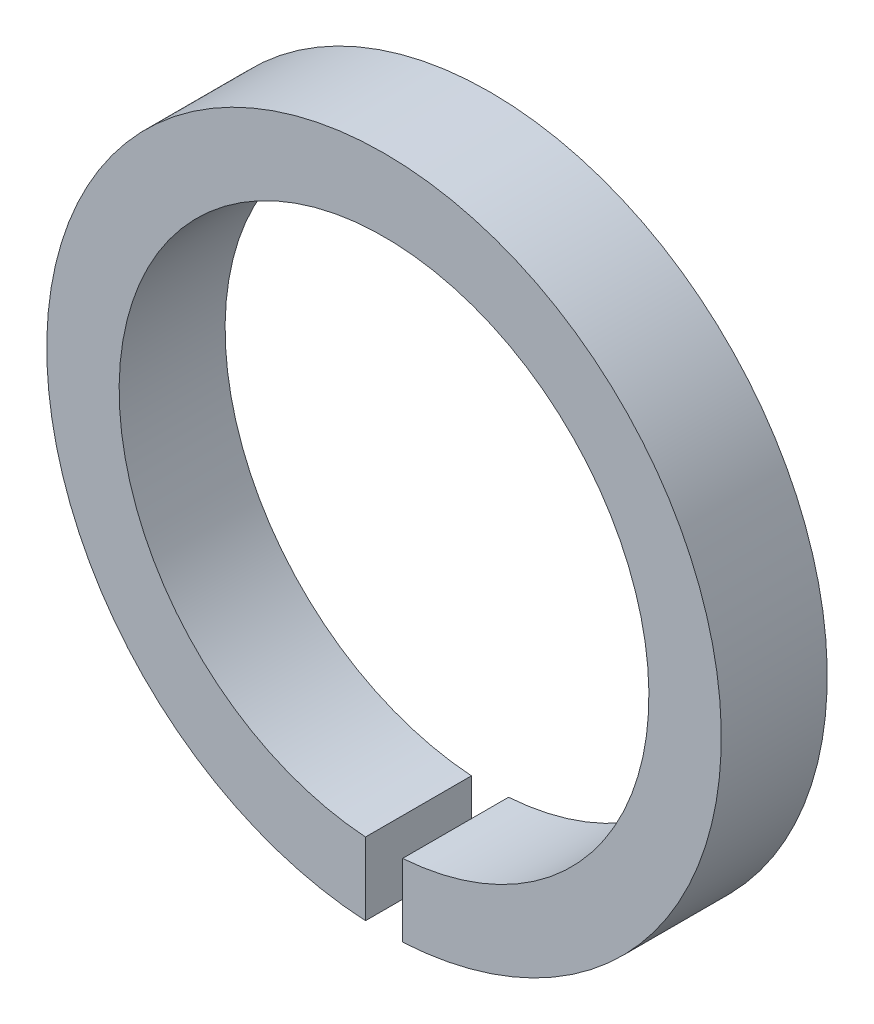
from build123d import *

# Parameters (mm, degrees)
SKETCH1_R           = 16.170418598
SKETCH1_R_2         = 12.7
BOSS_EXTRUDE1_DEPTH = 5.08
SKETCH2_W           = 1.778
SKETCH2_H           = 15.890272107
CUT_EXTRUDE1_DEPTH  = 5.08


with BuildPart() as part:
    # Sketch1 → Boss-Extrude1 (new body)
    with BuildSketch(Plane.XY):
        Circle(SKETCH1_R)
        Circle(SKETCH1_R_2, mode=Mode.SUBTRACT)
    extrude(amount=BOSS_EXTRUDE1_DEPTH)

    # Sketch2 → Cut-Extrude1 (cut)
    with BuildSketch(Plane.XY.offset(5.08)):
        with Locations((0, -8.90527334)):
            Rectangle(SKETCH2_W, SKETCH2_H)
    extrude(amount=-CUT_EXTRUDE1_DEPTH, mode=Mode.SUBTRACT)


solid = part.part
